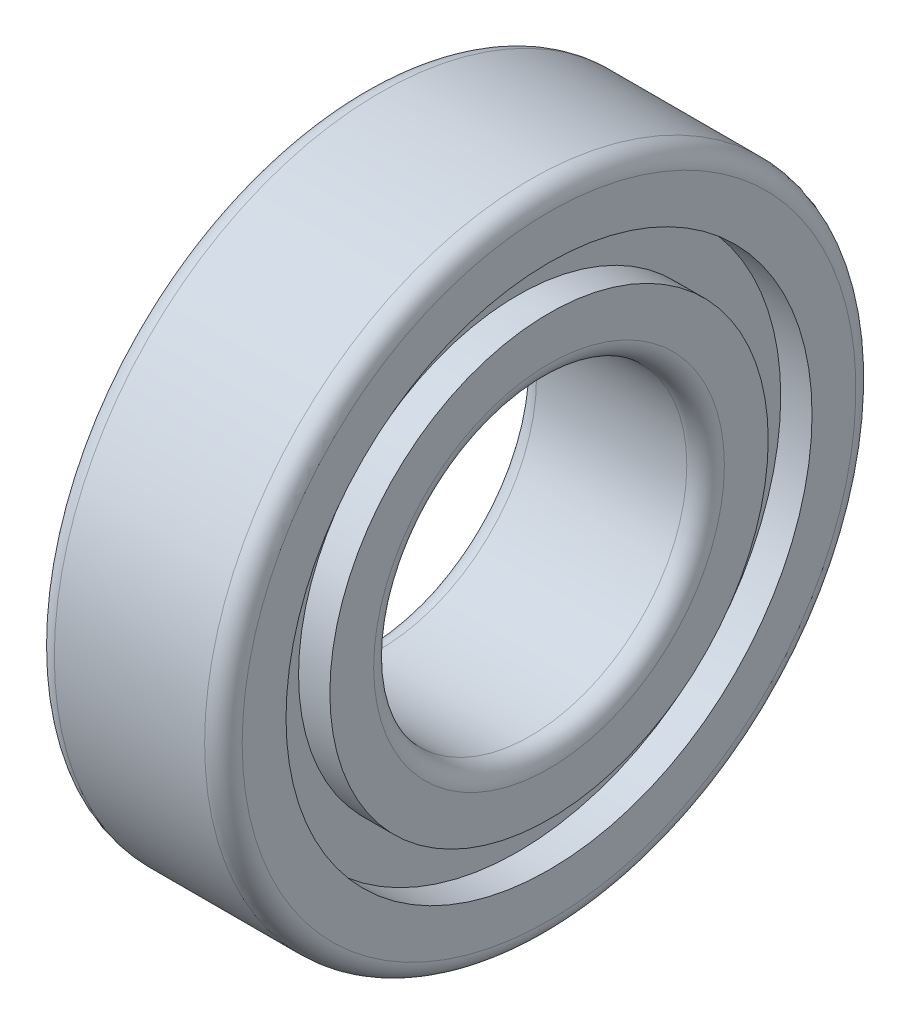
from build123d import *


with BuildPart() as part:
    # Эскиз1 → Повернуть1 (revolve)
    with BuildSketch(Plane.XY):
        with BuildLine():
            Line((6, 12.5), (-6, 12.5))
            ThreePointArc((-6, 12.5), (-7.060660172, 12.939339828), (-7.5, 14))
            Line((-7.5, 14), (-7.5, 17.5))
            Line((-7.5, 17.5), (-5, 17.5))
            Line((-5, 17.5), (-5, 21))
            Line((-5, 21), (-7.5, 21))
            Line((-7.5, 21), (-7.5, 24.5))
            ThreePointArc((-7.5, 24.5), (-7.060660172, 25.560660172), (-6, 26))
            Line((-6, 26), (6, 26))
            ThreePointArc((6, 26), (7.060660172, 25.560660172), (7.5, 24.5))
            Line((7.5, 24.5), (7.5, 21))
            Line((7.5, 21), (5, 21))
            Line((5, 21), (5, 17.5))
            Line((5, 17.5), (7.5, 17.5))
            Line((7.5, 17.5), (7.5, 14))
            ThreePointArc((7.5, 14), (7.060660172, 12.939339828), (6, 12.5))
        make_face()
    revolve(axis=Axis((-1000, 0, 0), (1, 0, 0)))


solid = part.part
